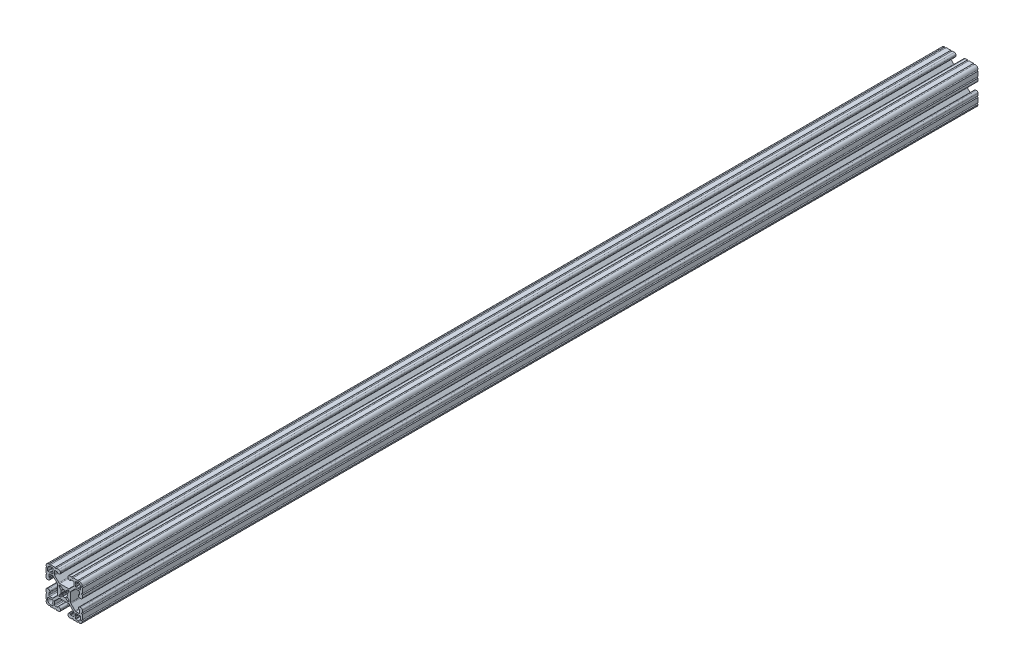
from build123d import *

# Parameters (mm, degrees)
BOSS_EXTRUDE1_DEPTH = 939.8


with BuildPart() as part:
    # Sketch1 → Boss-Extrude1 (new body)
    with BuildSketch(Plane(origin=(0, 0, -2322.576), x_dir=(-1, 0, 0), z_dir=(0, 0, -1))):
        with BuildLine():
            Line((19.05, -14.325600033), (19.05, -9.4996))
            ThreePointArc((19.05, -9.4996), (18.288, -8.7376), (19.05, -7.9756))
            Line((19.05, -7.9756), (19.05, -5.6388))
            ThreePointArc((19.05, -5.6388), (18.588751759, -4.525248241), (17.4752, -4.064))
            Line((17.4752, -4.064), (16.5608, -4.064))
            ThreePointArc((16.5608, -4.064), (15.447248241, -4.525248241), (14.986, -5.6388))
            Line((14.986, -5.6388), (14.986, -6.350014224))
            ThreePointArc((14.986, -6.350014224), (15.097592316, -6.619421908), (15.367, -6.731014224))
            Line((15.367, -6.731014224), (15.6972, -6.731014224))
            ThreePointArc((15.6972, -6.731014224), (15.966607684, -6.84260654), (16.0782, -7.112014224))
            Line((16.0782, -7.112014224), (16.0782, -9.398014224))
            ThreePointArc((16.0782, -9.398014224), (15.817817928, -10.026632152), (15.1892, -10.287014224))
            Line((15.1892, -10.287014224), (12.375630013, -10.287014224))
            ThreePointArc((12.375630013, -10.287014224), (11.889622054, -10.19034123), (11.477604401, -9.915039836))
            Line((11.477604401, -9.915039836), (7.115699788, -5.553135223))
            ThreePointArc((7.115699788, -5.553135223), (6.840398394, -5.14111757), (6.7437254, -4.655109611))
            Line((6.7437254, -4.655109611), (6.7437254, 4.655109611))
            ThreePointArc((6.7437254, 4.655109611), (6.840398394, 5.14111757), (7.115699788, 5.553135223))
            Line((7.115699788, 5.553135223), (11.477604401, 9.915039836))
            ThreePointArc((11.477604401, 9.915039836), (11.889622054, 10.19034123), (12.375630013, 10.287014224))
            Line((12.375630013, 10.287014224), (15.1892, 10.287014224))
            ThreePointArc((15.1892, 10.287014224), (15.817817928, 10.026632152), (16.0782, 9.398014224))
            Line((16.0782, 9.398014224), (16.0782, 7.112014224))
            ThreePointArc((16.0782, 7.112014224), (15.966607684, 6.84260654), (15.6972, 6.731014224))
            Line((15.6972, 6.731014224), (15.367, 6.731014224))
            ThreePointArc((15.367, 6.731014224), (15.097592316, 6.619421908), (14.986, 6.350014224))
            Line((14.986, 6.350014224), (14.986, 5.6388))
            ThreePointArc((14.986, 5.6388), (15.447248241, 4.525248241), (16.5608, 4.064))
            Line((16.5608, 4.064), (17.4752, 4.064))
            ThreePointArc((17.4752, 4.064), (18.588751759, 4.525248241), (19.05, 5.6388))
            Line((19.05, 5.6388), (19.05, 7.9756))
            ThreePointArc((19.05, 7.9756), (18.288, 8.7376), (19.05, 9.4996))
            Line((19.05, 9.4996), (19.05, 14.325599984))
            ThreePointArc((19.05, 14.325599984), (18.287999986, 15.087549208), (19.049898416, 15.849600009))
            ThreePointArc((19.049898416, 15.849600009), (18.120064036, 18.120064058), (15.849599977, 19.049898414))
            ThreePointArc((15.849599977, 19.049898414), (15.0875492, 18.288000035), (14.325600017, 19.050000016))
            Line((14.325600017, 19.050000016), (9.499600001, 19.050000016))
            ThreePointArc((9.499600001, 19.050000016), (8.737600001, 18.288000016), (7.975600001, 19.050000016))
            Line((7.975600001, 19.050000016), (5.638800016, 19.050000016))
            ThreePointArc((5.638800016, 19.050000016), (4.525248257, 18.588751775), (4.064000016, 17.475200016))
            Line((4.064000016, 17.475200016), (4.064000016, 16.5608))
            ThreePointArc((4.064000016, 16.5608), (4.525248257, 15.447248241), (5.638800016, 14.986))
            Line((5.638800016, 14.986), (6.350014224, 14.986))
            ThreePointArc((6.350014224, 14.986), (6.619421908, 15.097592316), (6.731014224, 15.367))
            Line((6.731014224, 15.367), (6.731014224, 15.6972))
            ThreePointArc((6.731014224, 15.6972), (6.84260654, 15.966607684), (7.112014224, 16.0782))
            Line((7.112014224, 16.0782), (9.398014224, 16.0782))
            ThreePointArc((9.398014224, 16.0782), (10.026632152, 15.817817928), (10.287014224, 15.1892))
            Line((10.287014224, 15.1892), (10.287014224, 12.375630013))
            ThreePointArc((10.287014224, 12.375630013), (10.19034123, 11.889622054), (9.915039836, 11.477604401))
            Line((9.915039836, 11.477604401), (5.553135223, 7.115699788))
            ThreePointArc((5.553135223, 7.115699788), (5.14111757, 6.840398394), (4.655109611, 6.7437254))
            Line((4.655109611, 6.7437254), (-4.655109611, 6.7437254))
            ThreePointArc((-4.655109611, 6.7437254), (-5.14111757, 6.840398394), (-5.553135223, 7.115699788))
            Line((-5.553135223, 7.115699788), (-9.915039836, 11.477604401))
            ThreePointArc((-9.915039836, 11.477604401), (-10.19034123, 11.889622054), (-10.287014224, 12.375630013))
            Line((-10.287014224, 12.375630013), (-10.287014224, 15.1892))
            ThreePointArc((-10.287014224, 15.1892), (-10.026632152, 15.817817928), (-9.398014224, 16.0782))
            Line((-9.398014224, 16.0782), (-7.112014224, 16.0782))
            ThreePointArc((-7.112014224, 16.0782), (-6.84260654, 15.966607684), (-6.731014224, 15.6972))
            Line((-6.731014224, 15.6972), (-6.731014224, 15.367))
            ThreePointArc((-6.731014224, 15.367), (-6.619421908, 15.097592316), (-6.350014224, 14.986))
            Line((-6.350014224, 14.986), (-5.638799984, 14.986))
            ThreePointArc((-5.638799984, 14.986), (-4.525248225, 15.447248241), (-4.063999984, 16.5608))
            Line((-4.063999984, 16.5608), (-4.063999984, 17.475200016))
            ThreePointArc((-4.063999984, 17.475200016), (-4.525248225, 18.588751775), (-5.638799984, 19.050000016))
            Line((-5.638799984, 19.050000016), (-7.975599999, 19.050000016))
            ThreePointArc((-7.975599999, 19.050000016), (-8.737599999, 18.288000016), (-9.499599999, 19.050000016))
            Line((-9.499599999, 19.050000016), (-14.325599999, 19.050000016))
            ThreePointArc((-14.325599999, 19.050000016), (-15.087549199, 18.288000018), (-15.849599993, 19.049898416))
            ThreePointArc((-15.849599993, 19.049898416), (-18.120064042, 18.120064036), (-19.049898398, 15.849599976))
            ThreePointArc((-19.049898398, 15.849599976), (-18.288000019, 15.087549199), (-19.05, 14.325600017))
            Line((-19.05, 14.325600017), (-19.05, 9.4996))
            ThreePointArc((-19.05, 9.4996), (-18.288, 8.7376), (-19.05, 7.9756))
            Line((-19.05, 7.9756), (-19.05, 5.6388))
            ThreePointArc((-19.05, 5.6388), (-18.588751759, 4.525248241), (-17.4752, 4.064))
            Line((-17.4752, 4.064), (-16.5608, 4.064))
            ThreePointArc((-16.5608, 4.064), (-15.447248241, 4.525248241), (-14.986, 5.6388))
            Line((-14.986, 5.6388), (-14.986, 6.350014224))
            ThreePointArc((-14.986, 6.350014224), (-15.097592316, 6.619421908), (-15.367, 6.731014224))
            Line((-15.367, 6.731014224), (-15.6972, 6.731014224))
            ThreePointArc((-15.6972, 6.731014224), (-15.966607684, 6.84260654), (-16.0782, 7.112014224))
            Line((-16.0782, 7.112014224), (-16.0782, 9.398014224))
            ThreePointArc((-16.0782, 9.398014224), (-15.817817928, 10.026632152), (-15.1892, 10.287014224))
            Line((-15.1892, 10.287014224), (-12.375630013, 10.287014224))
            ThreePointArc((-12.375630013, 10.287014224), (-11.889622054, 10.19034123), (-11.477604401, 9.915039836))
            Line((-11.477604401, 9.915039836), (-7.115699788, 5.553135223))
            ThreePointArc((-7.115699788, 5.553135223), (-6.840398394, 5.14111757), (-6.7437254, 4.655109611))
            Line((-6.7437254, 4.655109611), (-6.7437254, -4.655109611))
            ThreePointArc((-6.7437254, -4.655109611), (-6.840398394, -5.14111757), (-7.115699788, -5.553135223))
            Line((-7.115699788, -5.553135223), (-11.477604401, -9.915039836))
            ThreePointArc((-11.477604401, -9.915039836), (-11.889622054, -10.19034123), (-12.375630013, -10.287014224))
            Line((-12.375630013, -10.287014224), (-15.1892, -10.287014224))
            ThreePointArc((-15.1892, -10.287014224), (-15.817817928, -10.026632152), (-16.0782, -9.398014224))
            Line((-16.0782, -9.398014224), (-16.0782, -7.112014224))
            ThreePointArc((-16.0782, -7.112014224), (-15.966607684, -6.84260654), (-15.6972, -6.731014224))
            Line((-15.6972, -6.731014224), (-15.367, -6.731014224))
            ThreePointArc((-15.367, -6.731014224), (-15.097592316, -6.619421908), (-14.986, -6.350014224))
            Line((-14.986, -6.350014224), (-14.986, -5.6388))
            ThreePointArc((-14.986, -5.6388), (-15.447248241, -4.525248241), (-16.5608, -4.064))
            Line((-16.5608, -4.064), (-17.4752, -4.064))
            ThreePointArc((-17.4752, -4.064), (-18.588751759, -4.525248241), (-19.05, -5.6388))
            Line((-19.05, -5.6388), (-19.05, -7.9756))
            ThreePointArc((-19.05, -7.9756), (-18.288, -8.7376), (-19.05, -9.4996))
            Line((-19.05, -9.4996), (-19.05, -14.3256))
            ThreePointArc((-19.05, -14.3256), (-18.288000002, -15.0875492), (-19.0498984, -15.849599993))
            ThreePointArc((-19.0498984, -15.849599993), (-18.120064019, -18.120064043), (-15.84959996, -19.049898399))
            ThreePointArc((-15.84959996, -19.049898399), (-15.087549183, -18.288000019), (-14.325600001, -19.050000001))
            Line((-14.325600001, -19.050000001), (-9.499599984, -19.050000001))
            ThreePointArc((-9.499599984, -19.050000001), (-8.737599984, -18.288000001), (-7.975599984, -19.050000001))
            Line((-7.975599984, -19.050000001), (-5.638799984, -19.050000001))
            ThreePointArc((-5.638799984, -19.050000001), (-4.525248225, -18.58875176), (-4.063999984, -17.475200001))
            Line((-4.063999984, -17.475200001), (-4.063999984, -16.5608))
            ThreePointArc((-4.063999984, -16.5608), (-4.525248225, -15.447248241), (-5.638799984, -14.986))
            Line((-5.638799984, -14.986), (-6.350014224, -14.986))
            ThreePointArc((-6.350014224, -14.986), (-6.619421908, -15.097592316), (-6.731014224, -15.367))
            Line((-6.731014224, -15.367), (-6.731014224, -15.6972))
            ThreePointArc((-6.731014224, -15.6972), (-6.84260654, -15.966607684), (-7.112014224, -16.0782))
            Line((-7.112014224, -16.0782), (-9.398014224, -16.0782))
            ThreePointArc((-9.398014224, -16.0782), (-10.026632152, -15.817817928), (-10.287014224, -15.1892))
            Line((-10.287014224, -15.1892), (-10.287014224, -12.375630013))
            ThreePointArc((-10.287014224, -12.375630013), (-10.19034123, -11.889622054), (-9.915039836, -11.477604401))
            Line((-9.915039836, -11.477604401), (-5.553135223, -7.115699788))
            ThreePointArc((-5.553135223, -7.115699788), (-5.14111757, -6.840398394), (-4.655109611, -6.7437254))
            Line((-4.655109611, -6.7437254), (4.655109611, -6.7437254))
            ThreePointArc((4.655109611, -6.7437254), (5.14111757, -6.840398394), (5.553135223, -7.115699788))
            Line((5.553135223, -7.115699788), (9.915039836, -11.477604401))
            ThreePointArc((9.915039836, -11.477604401), (10.19034123, -11.889622054), (10.287014224, -12.375630013))
            Line((10.287014224, -12.375630013), (10.287014224, -15.1892))
            ThreePointArc((10.287014224, -15.1892), (10.026632152, -15.817817928), (9.398014224, -16.0782))
            Line((9.398014224, -16.0782), (7.112014224, -16.0782))
            ThreePointArc((7.112014224, -16.0782), (6.84260654, -15.966607684), (6.731014224, -15.6972))
            Line((6.731014224, -15.6972), (6.731014224, -15.367))
            ThreePointArc((6.731014224, -15.367), (6.619421908, -15.097592316), (6.350014224, -14.986))
            Line((6.350014224, -14.986), (5.638800016, -14.986))
            ThreePointArc((5.638800016, -14.986), (4.525248257, -15.447248241), (4.064000016, -16.5608))
            Line((4.064000016, -16.5608), (4.064000016, -17.475200001))
            ThreePointArc((4.064000016, -17.475200001), (4.525248257, -18.58875176), (5.638800016, -19.050000001))
            Line((5.638800016, -19.050000001), (7.975600016, -19.050000001))
            ThreePointArc((7.975600016, -19.050000001), (8.737600016, -18.288000001), (9.499600016, -19.050000001))
            Line((9.499600016, -19.050000001), (14.325600016, -19.050000001))
            ThreePointArc((14.325600016, -19.050000001), (15.087549216, -18.288000002), (15.849600009, -19.0498984))
            ThreePointArc((15.849600009, -19.0498984), (18.120064059, -18.12006402), (19.049898415, -15.849599961))
            ThreePointArc((19.049898415, -15.849599961), (18.288000034, -15.087549207), (19.05, -14.325600033))
        make_face()
        with BuildLine():
            Line((17.246614224, 14.452614224), (17.246614224, 12.242814224))
            ThreePointArc((17.246614224, 12.242814224), (17.135021908, 11.97340654), (16.865614224, 11.861814224))
            Line((16.865614224, 11.861814224), (15.092694224, 11.861814224))
            Line((15.092694224, 11.861814224), (14.554214224, 12.400294224))
            Line((14.554214224, 12.400294224), (14.015734224, 11.861814224))
            Line((14.015734224, 11.861814224), (12.242814224, 11.861814224))
            ThreePointArc((12.242814224, 11.861814224), (11.97340654, 11.97340654), (11.861814224, 12.242814224))
            Line((11.861814224, 12.242814224), (11.861814224, 14.015734224))
            Line((11.861814224, 14.015734224), (12.400294224, 14.554214224))
            Line((12.400294224, 14.554214224), (11.861814224, 15.092694224))
            Line((11.861814224, 15.092694224), (11.861814224, 16.865614224))
            ThreePointArc((11.861814224, 16.865614224), (11.97340654, 17.135021908), (12.242814224, 17.246614224))
            Line((12.242814224, 17.246614224), (14.452614224, 17.246614224))
            ThreePointArc((14.452614224, 17.246614224), (16.428270571, 16.428270571), (17.246614224, 14.452614224))
        make_face(mode=Mode.SUBTRACT)
        with BuildLine():
            Line((17.246614224, -12.242814224), (17.246614224, -14.452614224))
            ThreePointArc((17.246614224, -14.452614224), (16.428270571, -16.428270571), (14.452614224, -17.246614224))
            Line((14.452614224, -17.246614224), (12.242814224, -17.246614224))
            ThreePointArc((12.242814224, -17.246614224), (11.97340654, -17.135021908), (11.861814224, -16.865614224))
            Line((11.861814224, -16.865614224), (11.861814224, -15.092694224))
            Line((11.861814224, -15.092694224), (12.400294224, -14.554214224))
            Line((12.400294224, -14.554214224), (11.861814224, -14.015734224))
            Line((11.861814224, -14.015734224), (11.861814224, -12.242814224))
            ThreePointArc((11.861814224, -12.242814224), (11.97340654, -11.97340654), (12.242814224, -11.861814224))
            Line((12.242814224, -11.861814224), (14.015734224, -11.861814224))
            Line((14.015734224, -11.861814224), (14.554214224, -12.400294224))
            Line((14.554214224, -12.400294224), (15.092694224, -11.861814224))
            Line((15.092694224, -11.861814224), (16.865614224, -11.861814224))
            ThreePointArc((16.865614224, -11.861814224), (17.135021908, -11.97340654), (17.246614224, -12.242814224))
        make_face(mode=Mode.SUBTRACT)
        with BuildLine():
            Line((5.1689, -3.920689755), (5.1689, -4.9149))
            ThreePointArc((5.1689, -4.9149), (5.094505122, -5.094505122), (4.9149, -5.1689))
            Line((4.9149, -5.1689), (3.920689755, -5.1689))
            ThreePointArc((3.920689755, -5.1689), (3.580484184, -5.101228904), (3.292071827, -4.908517928))
            Line((3.292071827, -4.908517928), (1.582347442, -3.198793543))
            ThreePointArc((1.582347442, -3.198793543), (1.393016011, -3.095711236), (1.178048687, -3.111879183))
            ThreePointArc((1.178048687, -3.111879183), (0, -3.3274), (-1.178048687, -3.111879183))
            ThreePointArc((-1.178048687, -3.111879183), (-1.393016011, -3.095711236), (-1.582347442, -3.198793543))
            Line((-1.582347442, -3.198793543), (-3.292071827, -4.908517928))
            ThreePointArc((-3.292071827, -4.908517928), (-3.580484184, -5.101228904), (-3.920689755, -5.1689))
            Line((-3.920689755, -5.1689), (-4.9149, -5.1689))
            ThreePointArc((-4.9149, -5.1689), (-5.094505122, -5.094505122), (-5.1689, -4.9149))
            Line((-5.1689, -4.9149), (-5.1689, -3.920689755))
            ThreePointArc((-5.1689, -3.920689755), (-5.101228904, -3.580484184), (-4.908517928, -3.292071827))
            Line((-4.908517928, -3.292071827), (-3.198793543, -1.582347442))
            ThreePointArc((-3.198793543, -1.582347442), (-3.095711236, -1.393016011), (-3.111879183, -1.178048687))
            ThreePointArc((-3.111879183, -1.178048687), (-3.3274, 0), (-3.111879183, 1.178048687))
            ThreePointArc((-3.111879183, 1.178048687), (-3.095711236, 1.393016011), (-3.198793543, 1.582347442))
            Line((-3.198793543, 1.582347442), (-4.908517928, 3.292071827))
            ThreePointArc((-4.908517928, 3.292071827), (-5.101228904, 3.580484184), (-5.1689, 3.920689755))
            Line((-5.1689, 3.920689755), (-5.1689, 4.9149))
            ThreePointArc((-5.1689, 4.9149), (-5.094505122, 5.094505122), (-4.9149, 5.1689))
            Line((-4.9149, 5.1689), (-3.920689755, 5.1689))
            ThreePointArc((-3.920689755, 5.1689), (-3.580484184, 5.101228904), (-3.292071827, 4.908517928))
            Line((-3.292071827, 4.908517928), (-1.582347442, 3.198793543))
            ThreePointArc((-1.582347442, 3.198793543), (-1.393016011, 3.095711236), (-1.178048687, 3.111879183))
            ThreePointArc((-1.178048687, 3.111879183), (0, 3.3274), (1.178048687, 3.111879183))
            ThreePointArc((1.178048687, 3.111879183), (1.393016011, 3.095711236), (1.582347442, 3.198793543))
            Line((1.582347442, 3.198793543), (3.292071827, 4.908517928))
            ThreePointArc((3.292071827, 4.908517928), (3.580484184, 5.101228904), (3.920689755, 5.1689))
            Line((3.920689755, 5.1689), (4.9149, 5.1689))
            ThreePointArc((4.9149, 5.1689), (5.094505122, 5.094505122), (5.1689, 4.9149))
            Line((5.1689, 4.9149), (5.1689, 3.920689755))
            ThreePointArc((5.1689, 3.920689755), (5.101228904, 3.580484184), (4.908517928, 3.292071827))
            Line((4.908517928, 3.292071827), (3.198793543, 1.582347442))
            ThreePointArc((3.198793543, 1.582347442), (3.095711236, 1.393016011), (3.111879183, 1.178048687))
            ThreePointArc((3.111879183, 1.178048687), (3.3274, 0), (3.111879183, -1.178048687))
            ThreePointArc((3.111879183, -1.178048687), (3.095711236, -1.393016011), (3.198793543, -1.582347442))
            Line((3.198793543, -1.582347442), (4.908517928, -3.292071827))
            ThreePointArc((4.908517928, -3.292071827), (5.101228904, -3.580484184), (5.1689, -3.920689755))
        make_face(mode=Mode.SUBTRACT)
        with BuildLine():
            Line((-11.861814224, -12.242814224), (-11.861814224, -14.015734224))
            Line((-11.861814224, -14.015734224), (-12.400294224, -14.554214224))
            Line((-12.400294224, -14.554214224), (-11.861814224, -15.092694224))
            Line((-11.861814224, -15.092694224), (-11.861814224, -16.865614224))
            ThreePointArc((-11.861814224, -16.865614224), (-11.97340654, -17.135021908), (-12.242814224, -17.246614224))
            Line((-12.242814224, -17.246614224), (-14.452614224, -17.246614224))
            ThreePointArc((-14.452614224, -17.246614224), (-16.428270571, -16.428270571), (-17.246614224, -14.452614224))
            Line((-17.246614224, -14.452614224), (-17.246614224, -12.242814224))
            ThreePointArc((-17.246614224, -12.242814224), (-17.135021908, -11.97340654), (-16.865614224, -11.861814224))
            Line((-16.865614224, -11.861814224), (-15.092694224, -11.861814224))
            Line((-15.092694224, -11.861814224), (-14.554214224, -12.400294224))
            Line((-14.554214224, -12.400294224), (-14.015734224, -11.861814224))
            Line((-14.015734224, -11.861814224), (-12.242814224, -11.861814224))
            ThreePointArc((-12.242814224, -11.861814224), (-11.97340654, -11.97340654), (-11.861814224, -12.242814224))
        make_face(mode=Mode.SUBTRACT)
        with BuildLine():
            Line((-11.861814224, 16.865614224), (-11.861814224, 15.092694224))
            Line((-11.861814224, 15.092694224), (-12.400294224, 14.554214224))
            Line((-12.400294224, 14.554214224), (-11.861814224, 14.015734224))
            Line((-11.861814224, 14.015734224), (-11.861814224, 12.242814224))
            ThreePointArc((-11.861814224, 12.242814224), (-11.97340654, 11.97340654), (-12.242814224, 11.861814224))
            Line((-12.242814224, 11.861814224), (-14.015734224, 11.861814224))
            Line((-14.015734224, 11.861814224), (-14.554214224, 12.400294224))
            Line((-14.554214224, 12.400294224), (-15.092694224, 11.861814224))
            Line((-15.092694224, 11.861814224), (-16.865614224, 11.861814224))
            ThreePointArc((-16.865614224, 11.861814224), (-17.135021908, 11.97340654), (-17.246614224, 12.242814224))
            Line((-17.246614224, 12.242814224), (-17.246614224, 14.452614224))
            ThreePointArc((-17.246614224, 14.452614224), (-16.428270571, 16.428270571), (-14.452614224, 17.246614224))
            Line((-14.452614224, 17.246614224), (-12.242814224, 17.246614224))
            ThreePointArc((-12.242814224, 17.246614224), (-11.97340654, 17.135021908), (-11.861814224, 16.865614224))
        make_face(mode=Mode.SUBTRACT)
    extrude(amount=-BOSS_EXTRUDE1_DEPTH)


solid = part.part
